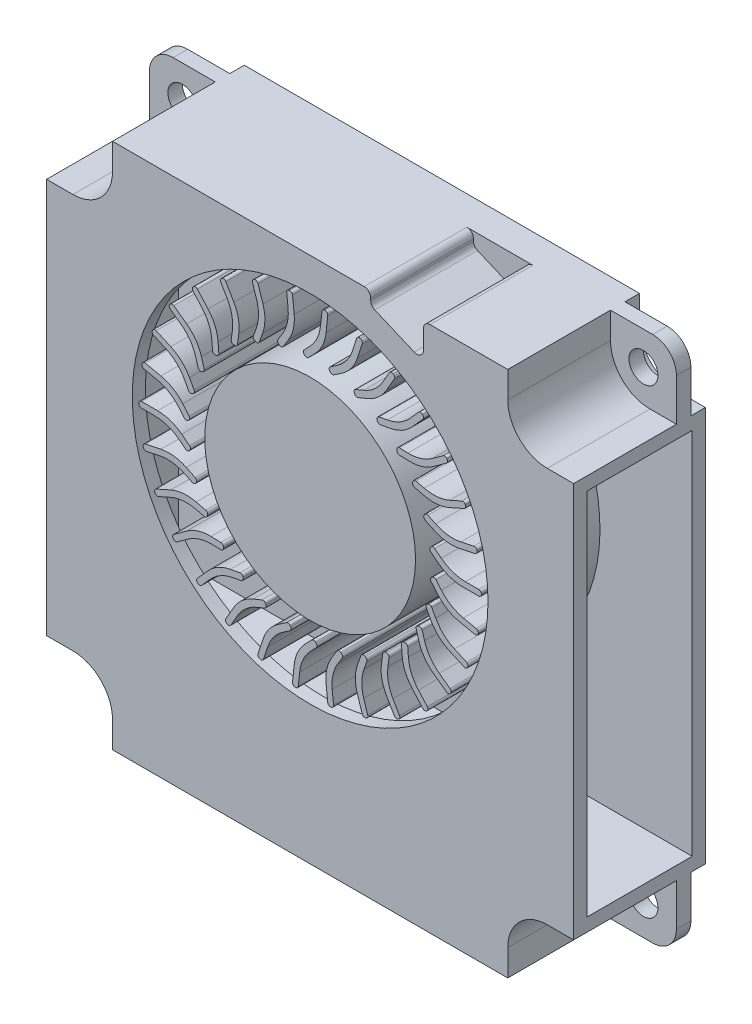
from build123d import *

# Parameters (mm, degrees)
SKETCH_1_R          = 1.1
EXTRUDE_1_DEPTH     = 1.1
EXTRUDE_2_DEPTH     = 7.8
EXTRUDE_3_DEPTH     = 1.1
SKETCH_4_W          = 8
SKETCH_4_H          = 28
CUT_EXTRUDE_1_DEPTH = 39
SKETCH_5_R          = 13.5
CUT_EXTRUDE_2_DEPTH = 9
SKETCH_6_R          = 13
EXTRUDE_4_DEPTH     = 1
SKETCH_7_R          = 8
EXTRUDE_5_DEPTH     = 8


with BuildPart() as part:
    # 草图1 → 凸台-拉伸1 (new body)
    with BuildSketch(Plane.XY):
        with BuildLine():
            Line((-18.2, 20), (18.2, 20))
            ThreePointArc((18.2, 20), (19.472792206, 19.472792206), (20, 18.2))
            Line((20, 18.2), (20, -18.2))
            ThreePointArc((20, -18.2), (19.472792206, -19.472792206), (18.2, -20))
            Line((18.2, -20), (-18.2, -20))
            ThreePointArc((-18.2, -20), (-19.472792206, -19.472792206), (-20, -18.2))
            Line((-20, -18.2), (-20, 18.2))
            ThreePointArc((-20, 18.2), (-19.472792206, 19.472792206), (-18.2, 20))
        make_face()
        with Locations((17.5, 17.5)):
            Circle(SKETCH_1_R, mode=Mode.SUBTRACT)
        with Locations((17.5, -17.5)):
            Circle(SKETCH_1_R, mode=Mode.SUBTRACT)
        with Locations((-17.5, -17.5)):
            Circle(SKETCH_1_R, mode=Mode.SUBTRACT)
        with Locations((-17.5, 17.5)):
            Circle(SKETCH_1_R, mode=Mode.SUBTRACT)
    extrude(amount=EXTRUDE_1_DEPTH)

    # 草图2 → 凸台-拉伸2 (add)
    with BuildSketch(Plane.XY.offset(1.1)):
        with BuildLine():
            Line((-20, 15), (-18, 15))
            ThreePointArc((-18, 15), (-15.878679656, 15.878679656), (-15, 18))
            Line((-15, 18), (-15, 20))
            Line((-15, 20), (4.1, 20))
            ThreePointArc((4.1, 20), (4.453553391, 19.853553391), (4.6, 19.5))
            Line((4.6, 19.5), (4.6, 19.330782845))
            ThreePointArc((4.6, 19.330782845), (4.682995707, 19.054907112), (4.90442968, 18.870617386))
            Line((4.90442968, 18.870617386), (7.90442968, 17.595617386))
            ThreePointArc((7.90442968, 17.595617386), (8.375875733, 17.638778553), (8.6, 18.055782845))
            Line((8.6, 18.055782845), (8.6, 19.5))
            ThreePointArc((8.6, 19.5), (8.746446609, 19.853553391), (9.1, 20))
            Line((9.1, 20), (15, 20))
            Line((15, 20), (15, 18))
            ThreePointArc((15, 18), (15.878679656, 15.878679656), (18, 15))
            Line((18, 15), (20, 15))
            Line((20, 15), (20, -15))
            Line((20, -15), (18, -15))
            ThreePointArc((18, -15), (15.878679656, -15.878679656), (15, -18))
            Line((15, -18), (15, -20))
            Line((15, -20), (-15, -20))
            Line((-15, -20), (-15, -18))
            ThreePointArc((-15, -18), (-15.878679656, -15.878679656), (-18, -15))
            Line((-18, -15), (-20, -15))
            Line((-20, -15), (-20, 15))
        make_face()
    extrude(amount=EXTRUDE_2_DEPTH)

    # 草图3 → 凸台-拉伸3 (add)
    with BuildSketch(Plane(origin=(0, 0, 0), x_dir=(-1, 0, 0), z_dir=(0, 0, -1))):
        with BuildLine():
            Line((-15, 20), (15, 20))
            Line((15, 20), (15, 18))
            ThreePointArc((15, 18), (15.878679656, 15.878679656), (18, 15))
            Line((18, 15), (20, 15))
            Line((20, 15), (20, -15))
            Line((20, -15), (18, -15))
            ThreePointArc((18, -15), (15.878679656, -15.878679656), (15, -18))
            Line((15, -18), (15, -20))
            Line((15, -20), (-15, -20))
            Line((-15, -20), (-15, -18))
            ThreePointArc((-15, -18), (-15.878679656, -15.878679656), (-18, -15))
            Line((-18, -15), (-20, -15))
            Line((-20, -15), (-20, 15))
            Line((-20, 15), (-18, 15))
            ThreePointArc((-18, 15), (-15.878679656, 15.878679656), (-15, 18))
            Line((-15, 18), (-15, 20))
        make_face()
    extrude(amount=EXTRUDE_3_DEPTH)

    # 草图4 → 切除-拉伸1 (cut)
    with BuildSketch(Plane(origin=(20, 0, 0), x_dir=(0, 0, -1), z_dir=(1, 0, 0))):
        with Locations((-3.9, 0)):
            Rectangle(SKETCH_4_W, SKETCH_4_H)
    extrude(amount=-CUT_EXTRUDE_1_DEPTH, mode=Mode.SUBTRACT)

    # 草图5 → 切除-拉伸2 (cut)
    with BuildSketch(Plane.XY.offset(8.9)):
        with Locations((0, 4)):
            Circle(SKETCH_5_R)
    extrude(amount=-CUT_EXTRUDE_2_DEPTH, mode=Mode.SUBTRACT)

    # 草图6 → 凸台-拉伸4 (add)
    with BuildSketch(Plane.XY.offset(-0.1)):
        with Locations((0, 4)):
            Circle(SKETCH_6_R)
    extrude(amount=EXTRUDE_4_DEPTH)

    # 草图7 → 凸台-拉伸5 (add)
    with BuildSketch(Plane.XY.offset(0.9)):
        with Locations((0, 4)):
            Circle(SKETCH_7_R)
        with BuildLine():
            Line((12.796562292, 4), (11.580714328, 4))
            ThreePointArc((11.580714328, 4), (10.611118595, 4.161006496), (9.745597002, 4.626743924))
            Line((9.745597002, 4.626743924), (9.158217072, 5.080934729))
            ThreePointArc((9.158217072, 5.080934729), (9.082173602, 5.213783697), (9.122341155, 5.361492956))
            Line((9.122341155, 5.361492956), (9.171307053, 5.424817852))
            ThreePointArc((9.171307053, 5.424817852), (9.30415602, 5.500861322), (9.451865279, 5.460693769))
            Line((9.451865279, 5.460693769), (9.95746241, 5.069741412))
            ThreePointArc((9.95746241, 5.069741412), (10.822984003, 4.604003985), (11.792579736, 4.442997488))
            Line((11.792579736, 4.442997488), (12.795829472, 4.442997488))
            ThreePointArc((12.795829472, 4.442997488), (12.936040681, 4.385618724), (12.995800431, 4.246405656))
            Line((12.995800431, 4.246405656), (12.996533251, 4.203408168))
            ThreePointArc((12.996533251, 4.203408168), (12.939183527, 4.059788791), (12.796562292, 4))
        make_face()
        with BuildLine():
            Line((12.516926703, 1.339445097), (11.327647935, 1.592234103))
            ThreePointArc((11.327647935, 1.592234103), (10.412715327, 1.95131251), (9.662939715, 2.586824515))
            Line((9.662939715, 2.586824515), (9.182827023, 3.153213316))
            ThreePointArc((9.182827023, 3.153213316), (9.136066139, 3.298969541), (9.206066416, 3.435099694))
            Line((9.206066416, 3.435099694), (9.267128278, 3.486860207))
            ThreePointArc((9.267128278, 3.486860207), (9.412884503, 3.533621091), (9.549014657, 3.463620814))
            Line((9.549014657, 3.463620814), (9.962279712, 2.97609215))
            ThreePointArc((9.962279712, 2.97609215), (10.712055325, 2.340580145), (11.626987932, 1.981501738))
            Line((11.626987932, 1.981501738), (12.608314254, 1.772914389))
            ThreePointArc((12.608314254, 1.772914389), (12.733531796, 1.687637939), (12.763041628, 1.53904226))
            Line((12.763041628, 1.53904226), (12.754818753, 1.496832008))
            ThreePointArc((12.754818753, 1.496832008), (12.668862111, 1.368274737), (12.516926703, 1.339445097))
        make_face()
        with BuildLine():
            Line((11.690241355, -1.204830789), (10.579508971, -0.71030087))
            ThreePointArc((10.579508971, -0.71030087), (9.759226434, -0.168844003), (9.157965593, 0.608667655))
            Line((9.157965593, 0.608667655), (8.806103369, 1.262500543))
            ThreePointArc((8.806103369, 1.262500543), (8.790668746, 1.41479378), (8.8874424, 1.533395287))
            Line((8.8874424, 1.533395287), (8.957931529, 1.571329233))
            ThreePointArc((8.957931529, 1.571329233), (9.110224765, 1.586763856), (9.228826272, 1.489990203))
            Line((9.228826272, 1.489990203), (9.531697586, 0.927192574))
            ThreePointArc((9.531697586, 0.927192574), (10.132958427, 0.149680915), (10.953240963, -0.391775952))
            Line((10.953240963, -0.391775952), (11.869755202, -0.799834382))
            ThreePointArc((11.869755202, -0.799834382), (11.97450647, -0.909281528), (11.972476662, -1.060765473))
            Line((11.972476662, -1.060765473), (11.955657472, -1.100343698))
            ThreePointArc((11.955657472, -1.100343698), (11.844850629, -1.208220294), (11.690241355, -1.204830789))
        make_face()
        with BuildLine():
            Line((10.352636364, -3.521630595), (9.368994698, -2.806973093))
            ThreePointArc((9.368994698, -2.806973093), (8.679212516, -2.106802028), (8.252744431, -1.221271707))
            Line((8.252744431, -1.221271707), (8.044510742, -0.508570366))
            ThreePointArc((8.044510742, -0.508570366), (8.061076946, -0.356396064), (8.180394503, -0.260506658))
            Line((8.180394503, -0.260506658), (8.257230187, -0.238057174))
            ThreePointArc((8.257230187, -0.238057174), (8.409404489, -0.254623378), (8.505293895, -0.373940935))
            Line((8.505293895, -0.373940935), (8.684534537, -0.987410573))
            ThreePointArc((8.684534537, -0.987410573), (9.111002622, -1.872940894), (9.800784804, -2.573111959))
            Line((9.800784804, -2.573111959), (10.612430891, -3.162807358))
            ThreePointArc((10.612430891, -3.162807358), (10.69213775, -3.291641835), (10.658657015, -3.439393472))
            Line((10.658657015, -3.439393472), (10.633976589, -3.474609911))
            ThreePointArc((10.633976589, -3.474609911), (10.503162336, -3.557091106), (10.352636364, -3.521630595))
        make_face()
        with BuildLine():
            Line((8.562571486, -5.509699051), (7.7490104, -4.606147928))
            ThreePointArc((7.7490104, -4.606147928), (7.219875364, -3.777863502), (6.986838736, -2.823016442))
            Line((6.986838736, -2.823016442), (6.931334393, -2.082595117))
            ThreePointArc((6.931334393, -2.082595117), (6.979177403, -1.937190495), (7.115824114, -1.868204019))
            Line((7.115824114, -1.868204019), (7.195648263, -1.862220146))
            ThreePointArc((7.195648263, -1.862220146), (7.341052884, -1.910063156), (7.410039361, -2.046709866))
            Line((7.410039361, -2.046709866), (7.457815656, -2.684039945))
            ThreePointArc((7.457815656, -2.684039945), (7.690852284, -3.638887005), (8.21998732, -4.467171432))
            Line((8.21998732, -4.467171432), (8.891292425, -5.212731282))
            ThreePointArc((8.891292425, -5.212731282), (8.942471304, -5.355322404), (8.879002911, -5.492884277))
            Line((8.879002911, -5.492884277), (8.847539902, -5.522199804))
            ThreePointArc((8.847539902, -5.522199804), (8.70243545, -5.575680774), (8.562571486, -5.509699051))
        make_face()
        with BuildLine():
            Line((6.398281146, -7.082148026), (5.790357164, -6.029192802))
            ThreePointArc((5.790357164, -6.029192802), (5.444995013, -5.108995017), (5.415574661, -4.126562617))
            Line((5.415574661, -4.126562617), (5.515225471, -3.390781273))
            ThreePointArc((5.515225471, -3.390781273), (5.592254317, -3.258501213), (5.740258064, -3.219432704))
            Line((5.740258064, -3.219432704), (5.819581982, -3.230175968))
            ThreePointArc((5.819581982, -3.230175968), (5.951862042, -3.307204814), (5.990930551, -3.455208561))
            Line((5.990930551, -3.455208561), (5.905154444, -4.088544698))
            ThreePointArc((5.905154444, -4.088544698), (5.934574796, -5.070977099), (6.279936947, -5.991174883))
            Line((6.279936947, -5.991174883), (6.781561815, -6.860014641))
            ThreePointArc((6.781561815, -6.860014641), (6.801975952, -7.010130493), (6.711293773, -7.131490488))
            Line((6.711293773, -7.131490488), (6.674423266, -7.153623872))
            ThreePointArc((6.674423266, -7.153623872), (6.521370375, -7.175767243), (6.398281146, -7.082148026))
        make_face()
        with BuildLine():
            Line((3.954355218, -8.170253954), (3.578637534, -7.013913825))
            ThreePointArc((3.578637534, -7.013913825), (3.432142253, -6.042019741), (3.607623987, -5.074939011))
            Line((3.607623987, -5.074939011), (3.858074731, -4.375954823))
            ThreePointArc((3.858074731, -4.375954823), (3.960922883, -4.262580597), (4.113815193, -4.255137538))
            Line((4.113815193, -4.255137538), (4.189172043, -4.282138405))
            ThreePointArc((4.189172043, -4.282138405), (4.302546269, -4.384986557), (4.309989327, -4.537878867))
            Line((4.309989327, -4.537878867), (4.094409647, -5.139541235))
            ThreePointArc((4.094409647, -5.139541235), (3.918927912, -6.106621965), (4.065423194, -7.078516049))
            Line((4.065423194, -7.078516049), (4.375444412, -8.032663248))
            ThreePointArc((4.375444412, -8.032663248), (4.364201611, -8.183743046), (4.250268894, -8.283597149))
            Line((4.250268894, -8.283597149), (4.209602306, -8.297581057))
            ThreePointArc((4.209602306, -8.297581057), (4.055290122, -8.287419057), (3.954355218, -8.170253954))
        make_face()
        with BuildLine():
            Line((1.337604991, -8.726461385), (1.210514272, -7.517273963))
            ThreePointArc((1.210514272, -7.517273963), (1.269288406, -6.536160015), (1.642002834, -5.626697023))
            Line((1.642002834, -5.626697023), (2.032307612, -4.995058954))
            ThreePointArc((2.032307612, -4.995058954), (2.156480112, -4.90554556), (2.307578857, -4.930053249))
            Line((2.307578857, -4.930053249), (2.375675183, -4.972131653))
            ThreePointArc((2.375675183, -4.972131653), (2.465188577, -5.096304153), (2.440680888, -5.247402898))
            Line((2.440680888, -5.247402898), (2.104719501, -5.791095964))
            ThreePointArc((2.104719501, -5.791095964), (1.732005073, -6.700558955), (1.67323094, -7.681672903))
            Line((1.67323094, -7.681672903), (1.778099093, -8.679426733))
            ThreePointArc((1.778099093, -8.679426733), (1.735690717, -8.824867564), (1.603486868, -8.898851672))
            Line((1.603486868, -8.898851672), (1.560801525, -8.904074938))
            ThreePointArc((1.560801525, -8.904074938), (1.411974231, -8.862051696), (1.337604991, -8.726461385))
        make_face()
        with BuildLine():
            Line((-1.337604991, -8.726461385), (-1.210514272, -7.517273963))
            ThreePointArc((-1.210514272, -7.517273963), (-0.949039434, -6.569819538), (-0.395381723, -5.757722182))
            Line((-0.395381723, -5.757722182), (0.117718899, -5.221035846))
            ThreePointArc((0.117718899, -5.221035846), (0.257788813, -5.159295449), (0.400490253, -5.214682782))
            Line((0.400490253, -5.214682782), (0.458349918, -5.269999694))
            ThreePointArc((0.458349918, -5.269999694), (0.520090315, -5.410069608), (0.464702983, -5.552771047))
            Line((0.464702983, -5.552771047), (0.023043013, -6.014732815))
            ThreePointArc((0.023043013, -6.014732815), (-0.530614698, -6.826830172), (-0.792089536, -7.774284597))
            Line((-0.792089536, -7.774284597), (-0.896957689, -8.772038426))
            ThreePointArc((-0.896957689, -8.772038426), (-0.968678189, -8.90548383), (-1.113375228, -8.950364481))
            Line((-1.113375228, -8.950364481), (-1.156213772, -8.946598825))
            ThreePointArc((-1.156213772, -8.946598825), (-1.293051709, -8.874550956), (-1.337604991, -8.726461385))
        make_face()
        with BuildLine():
            Line((-3.954355218, -8.170253954), (-3.578637534, -7.013913825))
            ThreePointArc((-3.578637534, -7.013913825), (-3.125889698, -6.141527228), (-2.415486201, -5.462288058))
            Line((-2.415486201, -5.462288058), (-1.802014696, -5.044009225))
            ThreePointArc((-1.802014696, -5.044009225), (-1.652169095, -5.012740176), (-1.524101698, -5.09658646))
            Line((-1.524101698, -5.09658646), (-1.479007437, -5.162724266))
            ThreePointArc((-1.479007437, -5.162724266), (-1.447738389, -5.312569866), (-1.531584673, -5.440637263))
            Line((-1.531584673, -5.440637263), (-2.059640565, -5.800677787))
            ThreePointArc((-2.059640565, -5.800677787), (-2.770044061, -6.479916957), (-3.222791898, -7.352303554))
            Line((-3.222791898, -7.352303554), (-3.532813116, -8.306450753))
            ThreePointArc((-3.532813116, -8.306450753), (-3.63071121, -8.422068524), (-3.781577484, -8.43588422))
            Line((-3.781577484, -8.43588422), (-3.822696979, -8.423294218))
            ThreePointArc((-3.822696979, -8.423294218), (-3.941565084, -8.324370562), (-3.954355218, -8.170253954))
        make_face()
        with BuildLine():
            Line((-6.398281146, -7.082148026), (-5.790357164, -6.029192802))
            ThreePointArc((-5.790357164, -6.029192802), (-5.166123581, -5.270001514), (-4.330022341, -4.753306541))
            Line((-4.330022341, -4.753306541), (-3.642991601, -4.471716002))
            ThreePointArc((-3.642991601, -4.471716002), (-3.489919285, -4.472284909), (-3.382083091, -4.58092566))
            Line((-3.382083091, -4.58092566), (-3.351725071, -4.654993819))
            ThreePointArc((-3.351725071, -4.654993819), (-3.352293978, -4.808066135), (-3.460934729, -4.915902329))
            Line((-3.460934729, -4.915902329), (-4.052307967, -5.158286111))
            ThreePointArc((-4.052307967, -5.158286111), (-4.888409207, -5.674981083), (-5.512642789, -6.434172372))
            Line((-5.512642789, -6.434172372), (-6.014267657, -7.30301213))
            ThreePointArc((-6.014267657, -7.30301213), (-6.13406473, -7.395749216), (-6.284506658, -7.377896144))
            Line((-6.284506658, -7.377896144), (-6.322109985, -7.35703204))
            ThreePointArc((-6.322109985, -7.35703204), (-6.417813152, -7.235556034), (-6.398281146, -7.082148026))
        make_face()
        with BuildLine():
            Line((-8.562571486, -5.509699051), (-7.7490104, -4.606147928))
            ThreePointArc((-7.7490104, -4.606147928), (-6.980573075, -3.993332251), (-6.055315727, -3.661763526))
            Line((-6.055315727, -3.661763526), (-5.324752292, -3.529168138))
            ThreePointArc((-5.324752292, -3.529168138), (-5.175143256, -3.561550138), (-5.092251223, -3.690237233))
            Line((-5.092251223, -3.690237233), (-5.077956235, -3.768998612))
            ThreePointArc((-5.077956235, -3.768998612), (-5.110338235, -3.918607648), (-5.23902533, -4.001499681))
            Line((-5.23902533, -4.001499681), (-5.867870065, -4.115633385))
            ThreePointArc((-5.867870065, -4.115633385), (-6.793127412, -4.44720211), (-7.561564738, -5.060017788))
            Line((-7.561564738, -5.060017788), (-8.232869842, -5.805577638))
            ThreePointArc((-8.232869842, -5.805577638), (-8.369330186, -5.871380985), (-8.512772734, -5.822639409))
            Line((-8.512772734, -5.822639409), (-8.545216447, -5.794413065))
            ThreePointArc((-8.545216447, -5.794413065), (-8.613571989, -5.655693794), (-8.562571486, -5.509699051))
        make_face()
        with BuildLine():
            Line((-10.352636364, -3.521630595), (-9.368994698, -2.806973093))
            ThreePointArc((-9.368994698, -2.806973093), (-8.489938028, -2.367316012), (-7.51596276, -2.235364679))
            Line((-7.51596276, -2.235364679), (-6.773795757, -2.257559498))
            ThreePointArc((-6.773795757, -2.257559498), (-6.634188634, -2.32033934), (-6.579863542, -2.463448536))
            Line((-6.579863542, -2.463448536), (-6.582256346, -2.543460886))
            ThreePointArc((-6.582256346, -2.543460886), (-6.645036188, -2.683068009), (-6.788145384, -2.7373931))
            Line((-6.788145384, -2.7373931), (-7.426978085, -2.718288537))
            ThreePointArc((-7.426978085, -2.718288537), (-8.400953353, -2.850239871), (-9.280010023, -3.289896952))
            Line((-9.280010023, -3.289896952), (-10.09165611, -3.879592351))
            ThreePointArc((-10.09165611, -3.879592351), (-10.238815752, -3.915586036), (-10.368989793, -3.838086198))
            Line((-10.368989793, -3.838086198), (-10.394855946, -3.80373124))
            ThreePointArc((-10.394855946, -3.80373124), (-10.432876397, -3.653831402), (-10.352636364, -3.521630595))
        make_face()
        with BuildLine():
            Line((-11.690241355, -1.204830789), (-10.579508971, -0.71030087))
            ThreePointArc((-10.579508971, -0.71030087), (-9.628251951, -0.46301751), (-8.648126154, -0.536450475))
            Line((-8.648126154, -0.536450475), (-7.926791843, -0.71246548))
            ThreePointArc((-7.926791843, -0.71246548), (-7.803288133, -0.802899386), (-7.779904251, -0.954176124))
            Line((-7.779904251, -0.954176124), (-7.798880269, -1.03194252))
            ThreePointArc((-7.798880269, -1.03194252), (-7.889314174, -1.155446229), (-8.040590912, -1.178830112))
            Line((-8.040590912, -1.178830112), (-8.661491524, -1.027322243))
            ThreePointArc((-8.661491524, -1.027322243), (-9.64161732, -0.953889278), (-10.59287434, -1.201172638))
            Line((-10.59287434, -1.201172638), (-11.50938858, -1.609231068))
            ThreePointArc((-11.50938858, -1.609231068), (-11.660815939, -1.613841995), (-11.772032243, -1.510971009))
            Line((-11.772032243, -1.510971009), (-11.790190361, -1.471988914))
            ThreePointArc((-11.790190361, -1.471988914), (-11.796214045, -1.31745985), (-11.690241355, -1.204830789))
        make_face()
        with BuildLine():
            Line((-12.516926703, 1.339445097), (-11.327647935, 1.592234103))
            ThreePointArc((-11.327647935, 1.592234103), (-10.345765061, 1.636336273), (-9.402324937, 1.360728384))
            Line((-9.402324937, 1.360728384), (-8.733349089, 1.038585892))
            ThreePointArc((-8.733349089, 1.038585892), (-8.631346498, 0.924450319), (-8.639925811, 0.771617558))
            Line((-8.639925811, 0.771617558), (-8.6746557, 0.69949588))
            ThreePointArc((-8.6746557, 0.69949588), (-8.788791273, 0.597493289), (-8.941624034, 0.606072603))
            Line((-8.941624034, 0.606072603), (-9.51745622, 0.883362158))
            ThreePointArc((-9.51745622, 0.883362158), (-10.460896345, 1.158970048), (-11.442779218, 1.114867878))
            Line((-11.442779218, 1.114867878), (-12.424105541, 0.906280529))
            ThreePointArc((-12.424105541, 0.906280529), (-12.573182515, 0.93325388), (-12.660580395, 1.057000057))
            Line((-12.660580395, 1.057000057), (-12.670236881, 1.098905586))
            ThreePointArc((-12.670236881, 1.098905586), (-12.644000534, 1.251310213), (-12.516926703, 1.339445097))
        make_face()
        with BuildLine():
            Line((-12.796562292, 4), (-11.580714328, 4))
            ThreePointArc((-11.580714328, 4), (-10.611118595, 3.838993504), (-9.745597002, 3.373256076))
            Line((-9.745597002, 3.373256076), (-9.158217072, 2.919065271))
            ThreePointArc((-9.158217072, 2.919065271), (-9.082173602, 2.786216303), (-9.122341155, 2.638507044))
            Line((-9.122341155, 2.638507044), (-9.171307053, 2.575182148))
            ThreePointArc((-9.171307053, 2.575182148), (-9.30415602, 2.499138678), (-9.451865279, 2.539306231))
            Line((-9.451865279, 2.539306231), (-9.95746241, 2.930258588))
            ThreePointArc((-9.95746241, 2.930258588), (-10.822984003, 3.395996015), (-11.792579736, 3.557002512))
            Line((-11.792579736, 3.557002512), (-12.795829472, 3.557002512))
            ThreePointArc((-12.795829472, 3.557002512), (-12.936040681, 3.614381276), (-12.995800431, 3.753594344))
            Line((-12.995800431, 3.753594344), (-12.996533251, 3.796591832))
            ThreePointArc((-12.996533251, 3.796591832), (-12.939183527, 3.940211209), (-12.796562292, 4))
        make_face()
        with BuildLine():
            Line((-12.516926703, 6.660554903), (-11.327647935, 6.407765897))
            ThreePointArc((-11.327647935, 6.407765897), (-10.412715327, 6.04868749), (-9.662939715, 5.413175485))
            Line((-9.662939715, 5.413175485), (-9.182827023, 4.846786684))
            ThreePointArc((-9.182827023, 4.846786684), (-9.136066139, 4.701030459), (-9.206066416, 4.564900306))
            Line((-9.206066416, 4.564900306), (-9.267128278, 4.513139793))
            ThreePointArc((-9.267128278, 4.513139793), (-9.412884503, 4.466378909), (-9.549014657, 4.536379186))
            Line((-9.549014657, 4.536379186), (-9.962279712, 5.02390785))
            ThreePointArc((-9.962279712, 5.02390785), (-10.712055325, 5.659419855), (-11.626987932, 6.018498262))
            Line((-11.626987932, 6.018498262), (-12.608314254, 6.227085611))
            ThreePointArc((-12.608314254, 6.227085611), (-12.733531796, 6.312362061), (-12.763041628, 6.46095774))
            Line((-12.763041628, 6.46095774), (-12.754818753, 6.503167992))
            ThreePointArc((-12.754818753, 6.503167992), (-12.668862111, 6.631725263), (-12.516926703, 6.660554903))
        make_face()
        with BuildLine():
            Line((-11.690241355, 9.204830789), (-10.579508971, 8.71030087))
            ThreePointArc((-10.579508971, 8.71030087), (-9.759226434, 8.168844003), (-9.157965593, 7.391332345))
            Line((-9.157965593, 7.391332345), (-8.806103369, 6.737499457))
            ThreePointArc((-8.806103369, 6.737499457), (-8.790668746, 6.58520622), (-8.8874424, 6.466604713))
            Line((-8.8874424, 6.466604713), (-8.957931529, 6.428670767))
            ThreePointArc((-8.957931529, 6.428670767), (-9.110224765, 6.413236144), (-9.228826272, 6.510009797))
            Line((-9.228826272, 6.510009797), (-9.531697586, 7.072807426))
            ThreePointArc((-9.531697586, 7.072807426), (-10.132958427, 7.850319085), (-10.953240963, 8.391775952))
            Line((-10.953240963, 8.391775952), (-11.869755202, 8.799834382))
            ThreePointArc((-11.869755202, 8.799834382), (-11.97450647, 8.909281528), (-11.972476662, 9.060765473))
            Line((-11.972476662, 9.060765473), (-11.955657472, 9.100343698))
            ThreePointArc((-11.955657472, 9.100343698), (-11.844850629, 9.208220294), (-11.690241355, 9.204830789))
        make_face()
        with BuildLine():
            Line((-10.352636364, 11.521630595), (-9.368994698, 10.806973093))
            ThreePointArc((-9.368994698, 10.806973093), (-8.679212516, 10.106802028), (-8.252744431, 9.221271707))
            Line((-8.252744431, 9.221271707), (-8.044510742, 8.508570366))
            ThreePointArc((-8.044510742, 8.508570366), (-8.061076946, 8.356396064), (-8.180394503, 8.260506658))
            Line((-8.180394503, 8.260506658), (-8.257230187, 8.238057174))
            ThreePointArc((-8.257230187, 8.238057174), (-8.409404489, 8.254623378), (-8.505293895, 8.373940935))
            Line((-8.505293895, 8.373940935), (-8.684534537, 8.987410573))
            ThreePointArc((-8.684534537, 8.987410573), (-9.111002622, 9.872940894), (-9.800784804, 10.573111959))
            Line((-9.800784804, 10.573111959), (-10.612430891, 11.162807358))
            ThreePointArc((-10.612430891, 11.162807358), (-10.69213775, 11.291641835), (-10.658657015, 11.439393472))
            Line((-10.658657015, 11.439393472), (-10.633976589, 11.474609911))
            ThreePointArc((-10.633976589, 11.474609911), (-10.503162336, 11.557091106), (-10.352636364, 11.521630595))
        make_face()
        with BuildLine():
            Line((-8.562571486, 13.509699051), (-7.7490104, 12.606147928))
            ThreePointArc((-7.7490104, 12.606147928), (-7.219875364, 11.777863502), (-6.986838736, 10.823016442))
            Line((-6.986838736, 10.823016442), (-6.931334393, 10.082595117))
            ThreePointArc((-6.931334393, 10.082595117), (-6.979177403, 9.937190495), (-7.115824114, 9.868204019))
            Line((-7.115824114, 9.868204019), (-7.195648263, 9.862220146))
            ThreePointArc((-7.195648263, 9.862220146), (-7.341052884, 9.910063156), (-7.410039361, 10.046709866))
            Line((-7.410039361, 10.046709866), (-7.457815656, 10.684039945))
            ThreePointArc((-7.457815656, 10.684039945), (-7.690852284, 11.638887005), (-8.21998732, 12.467171432))
            Line((-8.21998732, 12.467171432), (-8.891292425, 13.212731282))
            ThreePointArc((-8.891292425, 13.212731282), (-8.942471304, 13.355322404), (-8.879002911, 13.492884277))
            Line((-8.879002911, 13.492884277), (-8.847539902, 13.522199804))
            ThreePointArc((-8.847539902, 13.522199804), (-8.70243545, 13.575680774), (-8.562571486, 13.509699051))
        make_face()
        with BuildLine():
            Line((-6.398281146, 15.082148026), (-5.790357164, 14.029192802))
            ThreePointArc((-5.790357164, 14.029192802), (-5.444995013, 13.108995017), (-5.415574661, 12.126562617))
            Line((-5.415574661, 12.126562617), (-5.515225471, 11.390781273))
            ThreePointArc((-5.515225471, 11.390781273), (-5.592254317, 11.258501213), (-5.740258064, 11.219432704))
            Line((-5.740258064, 11.219432704), (-5.819581982, 11.230175968))
            ThreePointArc((-5.819581982, 11.230175968), (-5.951862042, 11.307204814), (-5.990930551, 11.455208561))
            Line((-5.990930551, 11.455208561), (-5.905154444, 12.088544698))
            ThreePointArc((-5.905154444, 12.088544698), (-5.934574796, 13.070977099), (-6.279936947, 13.991174883))
            Line((-6.279936947, 13.991174883), (-6.781561815, 14.860014641))
            ThreePointArc((-6.781561815, 14.860014641), (-6.801975952, 15.010130493), (-6.711293773, 15.131490488))
            Line((-6.711293773, 15.131490488), (-6.674423266, 15.153623872))
            ThreePointArc((-6.674423266, 15.153623872), (-6.521370375, 15.175767243), (-6.398281146, 15.082148026))
        make_face()
        with BuildLine():
            Line((-3.954355218, 16.170253954), (-3.578637534, 15.013913825))
            ThreePointArc((-3.578637534, 15.013913825), (-3.432142253, 14.042019741), (-3.607623987, 13.074939011))
            Line((-3.607623987, 13.074939011), (-3.858074731, 12.375954823))
            ThreePointArc((-3.858074731, 12.375954823), (-3.960922883, 12.262580597), (-4.113815193, 12.255137538))
            Line((-4.113815193, 12.255137538), (-4.189172043, 12.282138405))
            ThreePointArc((-4.189172043, 12.282138405), (-4.302546269, 12.384986557), (-4.309989327, 12.537878867))
            Line((-4.309989327, 12.537878867), (-4.094409647, 13.139541235))
            ThreePointArc((-4.094409647, 13.139541235), (-3.918927912, 14.106621965), (-4.065423194, 15.078516049))
            Line((-4.065423194, 15.078516049), (-4.375444412, 16.032663248))
            ThreePointArc((-4.375444412, 16.032663248), (-4.364201611, 16.183743046), (-4.250268894, 16.283597149))
            Line((-4.250268894, 16.283597149), (-4.209602306, 16.297581057))
            ThreePointArc((-4.209602306, 16.297581057), (-4.055290122, 16.287419057), (-3.954355218, 16.170253954))
        make_face()
        with BuildLine():
            Line((-1.337604991, 16.726461385), (-1.210514272, 15.517273963))
            ThreePointArc((-1.210514272, 15.517273963), (-1.269288406, 14.536160015), (-1.642002834, 13.626697023))
            Line((-1.642002834, 13.626697023), (-2.032307612, 12.995058954))
            ThreePointArc((-2.032307612, 12.995058954), (-2.156480112, 12.90554556), (-2.307578857, 12.930053249))
            Line((-2.307578857, 12.930053249), (-2.375675183, 12.972131653))
            ThreePointArc((-2.375675183, 12.972131653), (-2.465188577, 13.096304153), (-2.440680888, 13.247402898))
            Line((-2.440680888, 13.247402898), (-2.104719501, 13.791095964))
            ThreePointArc((-2.104719501, 13.791095964), (-1.732005073, 14.700558955), (-1.67323094, 15.681672903))
            Line((-1.67323094, 15.681672903), (-1.778099093, 16.679426733))
            ThreePointArc((-1.778099093, 16.679426733), (-1.735690717, 16.824867564), (-1.603486868, 16.898851672))
            Line((-1.603486868, 16.898851672), (-1.560801525, 16.904074938))
            ThreePointArc((-1.560801525, 16.904074938), (-1.411974231, 16.862051696), (-1.337604991, 16.726461385))
        make_face()
        with BuildLine():
            Line((1.337604991, 16.726461385), (1.210514272, 15.517273963))
            ThreePointArc((1.210514272, 15.517273963), (0.949039434, 14.569819538), (0.395381723, 13.757722182))
            Line((0.395381723, 13.757722182), (-0.117718899, 13.221035846))
            ThreePointArc((-0.117718899, 13.221035846), (-0.257788813, 13.159295449), (-0.400490253, 13.214682782))
            Line((-0.400490253, 13.214682782), (-0.458349918, 13.269999694))
            ThreePointArc((-0.458349918, 13.269999694), (-0.520090315, 13.410069608), (-0.464702983, 13.552771047))
            Line((-0.464702983, 13.552771047), (-0.023043013, 14.014732815))
            ThreePointArc((-0.023043013, 14.014732815), (0.530614698, 14.826830172), (0.792089536, 15.774284597))
            Line((0.792089536, 15.774284597), (0.896957689, 16.772038426))
            ThreePointArc((0.896957689, 16.772038426), (0.968678189, 16.90548383), (1.113375228, 16.950364481))
            Line((1.113375228, 16.950364481), (1.156213772, 16.946598825))
            ThreePointArc((1.156213772, 16.946598825), (1.293051709, 16.874550956), (1.337604991, 16.726461385))
        make_face()
        with BuildLine():
            Line((3.954355218, 16.170253954), (3.578637534, 15.013913825))
            ThreePointArc((3.578637534, 15.013913825), (3.125889698, 14.141527228), (2.415486201, 13.462288058))
            Line((2.415486201, 13.462288058), (1.802014696, 13.044009225))
            ThreePointArc((1.802014696, 13.044009225), (1.652169095, 13.012740176), (1.524101698, 13.09658646))
            Line((1.524101698, 13.09658646), (1.479007437, 13.162724266))
            ThreePointArc((1.479007437, 13.162724266), (1.447738389, 13.312569866), (1.531584673, 13.440637263))
            Line((1.531584673, 13.440637263), (2.059640565, 13.800677787))
            ThreePointArc((2.059640565, 13.800677787), (2.770044061, 14.479916957), (3.222791898, 15.352303554))
            Line((3.222791898, 15.352303554), (3.532813116, 16.306450753))
            ThreePointArc((3.532813116, 16.306450753), (3.63071121, 16.422068524), (3.781577484, 16.43588422))
            Line((3.781577484, 16.43588422), (3.822696979, 16.423294218))
            ThreePointArc((3.822696979, 16.423294218), (3.941565084, 16.324370562), (3.954355218, 16.170253954))
        make_face()
        with BuildLine():
            Line((6.398281146, 15.082148026), (5.790357164, 14.029192802))
            ThreePointArc((5.790357164, 14.029192802), (5.166123581, 13.270001514), (4.330022341, 12.753306541))
            Line((4.330022341, 12.753306541), (3.642991601, 12.471716002))
            ThreePointArc((3.642991601, 12.471716002), (3.489919285, 12.472284909), (3.382083091, 12.58092566))
            Line((3.382083091, 12.58092566), (3.351725071, 12.654993819))
            ThreePointArc((3.351725071, 12.654993819), (3.352293978, 12.808066135), (3.460934729, 12.915902329))
            Line((3.460934729, 12.915902329), (4.052307967, 13.158286111))
            ThreePointArc((4.052307967, 13.158286111), (4.888409207, 13.674981083), (5.512642789, 14.434172372))
            Line((5.512642789, 14.434172372), (6.014267657, 15.30301213))
            ThreePointArc((6.014267657, 15.30301213), (6.13406473, 15.395749216), (6.284506658, 15.377896144))
            Line((6.284506658, 15.377896144), (6.322109985, 15.35703204))
            ThreePointArc((6.322109985, 15.35703204), (6.417813152, 15.235556034), (6.398281146, 15.082148026))
        make_face()
        with BuildLine():
            Line((8.562571486, 13.509699051), (7.7490104, 12.606147928))
            ThreePointArc((7.7490104, 12.606147928), (6.980573075, 11.993332251), (6.055315727, 11.661763526))
            Line((6.055315727, 11.661763526), (5.324752292, 11.529168138))
            ThreePointArc((5.324752292, 11.529168138), (5.175143256, 11.561550138), (5.092251223, 11.690237233))
            Line((5.092251223, 11.690237233), (5.077956235, 11.768998612))
            ThreePointArc((5.077956235, 11.768998612), (5.110338235, 11.918607648), (5.23902533, 12.001499681))
            Line((5.23902533, 12.001499681), (5.867870065, 12.115633385))
            ThreePointArc((5.867870065, 12.115633385), (6.793127412, 12.44720211), (7.561564738, 13.060017788))
            Line((7.561564738, 13.060017788), (8.232869842, 13.805577638))
            ThreePointArc((8.232869842, 13.805577638), (8.369330186, 13.871380985), (8.512772734, 13.822639409))
            Line((8.512772734, 13.822639409), (8.545216447, 13.794413065))
            ThreePointArc((8.545216447, 13.794413065), (8.613571989, 13.655693794), (8.562571486, 13.509699051))
        make_face()
        with BuildLine():
            Line((10.352636364, 11.521630595), (9.368994698, 10.806973093))
            ThreePointArc((9.368994698, 10.806973093), (8.489938028, 10.367316012), (7.51596276, 10.235364679))
            Line((7.51596276, 10.235364679), (6.773795757, 10.257559498))
            ThreePointArc((6.773795757, 10.257559498), (6.634188634, 10.32033934), (6.579863542, 10.463448536))
            Line((6.579863542, 10.463448536), (6.582256346, 10.543460886))
            ThreePointArc((6.582256346, 10.543460886), (6.645036188, 10.683068009), (6.788145384, 10.7373931))
            Line((6.788145384, 10.7373931), (7.426978085, 10.718288537))
            ThreePointArc((7.426978085, 10.718288537), (8.400953353, 10.850239871), (9.280010023, 11.289896952))
            Line((9.280010023, 11.289896952), (10.09165611, 11.879592351))
            ThreePointArc((10.09165611, 11.879592351), (10.238815752, 11.915586036), (10.368989793, 11.838086198))
            Line((10.368989793, 11.838086198), (10.394855946, 11.80373124))
            ThreePointArc((10.394855946, 11.80373124), (10.432876397, 11.653831402), (10.352636364, 11.521630595))
        make_face()
        with BuildLine():
            Line((11.690241355, 9.204830789), (10.579508971, 8.71030087))
            ThreePointArc((10.579508971, 8.71030087), (9.628251951, 8.46301751), (8.648126154, 8.536450475))
            Line((8.648126154, 8.536450475), (7.926791843, 8.71246548))
            ThreePointArc((7.926791843, 8.71246548), (7.803288133, 8.802899386), (7.779904251, 8.954176124))
            Line((7.779904251, 8.954176124), (7.798880269, 9.03194252))
            ThreePointArc((7.798880269, 9.03194252), (7.889314174, 9.155446229), (8.040590912, 9.178830112))
            Line((8.040590912, 9.178830112), (8.661491524, 9.027322243))
            ThreePointArc((8.661491524, 9.027322243), (9.64161732, 8.953889278), (10.59287434, 9.201172638))
            Line((10.59287434, 9.201172638), (11.50938858, 9.609231068))
            ThreePointArc((11.50938858, 9.609231068), (11.660815939, 9.613841995), (11.772032243, 9.510971009))
            Line((11.772032243, 9.510971009), (11.790190361, 9.471988914))
            ThreePointArc((11.790190361, 9.471988914), (11.796214045, 9.31745985), (11.690241355, 9.204830789))
        make_face()
        with BuildLine():
            Line((12.516926703, 6.660554903), (11.327647935, 6.407765897))
            ThreePointArc((11.327647935, 6.407765897), (10.345765061, 6.363663727), (9.402324937, 6.639271616))
            Line((9.402324937, 6.639271616), (8.733349089, 6.961414108))
            ThreePointArc((8.733349089, 6.961414108), (8.631346498, 7.075549681), (8.639925811, 7.228382442))
            Line((8.639925811, 7.228382442), (8.6746557, 7.30050412))
            ThreePointArc((8.6746557, 7.30050412), (8.788791273, 7.402506711), (8.941624034, 7.393927397))
            Line((8.941624034, 7.393927397), (9.51745622, 7.116637842))
            ThreePointArc((9.51745622, 7.116637842), (10.460896345, 6.841029952), (11.442779218, 6.885132122))
            Line((11.442779218, 6.885132122), (12.424105541, 7.093719471))
            ThreePointArc((12.424105541, 7.093719471), (12.573182515, 7.06674612), (12.660580395, 6.942999943))
            Line((12.660580395, 6.942999943), (12.670236881, 6.901094414))
            ThreePointArc((12.670236881, 6.901094414), (12.644000534, 6.748689787), (12.516926703, 6.660554903))
        make_face()
    extrude(amount=EXTRUDE_5_DEPTH)


solid = part.part
